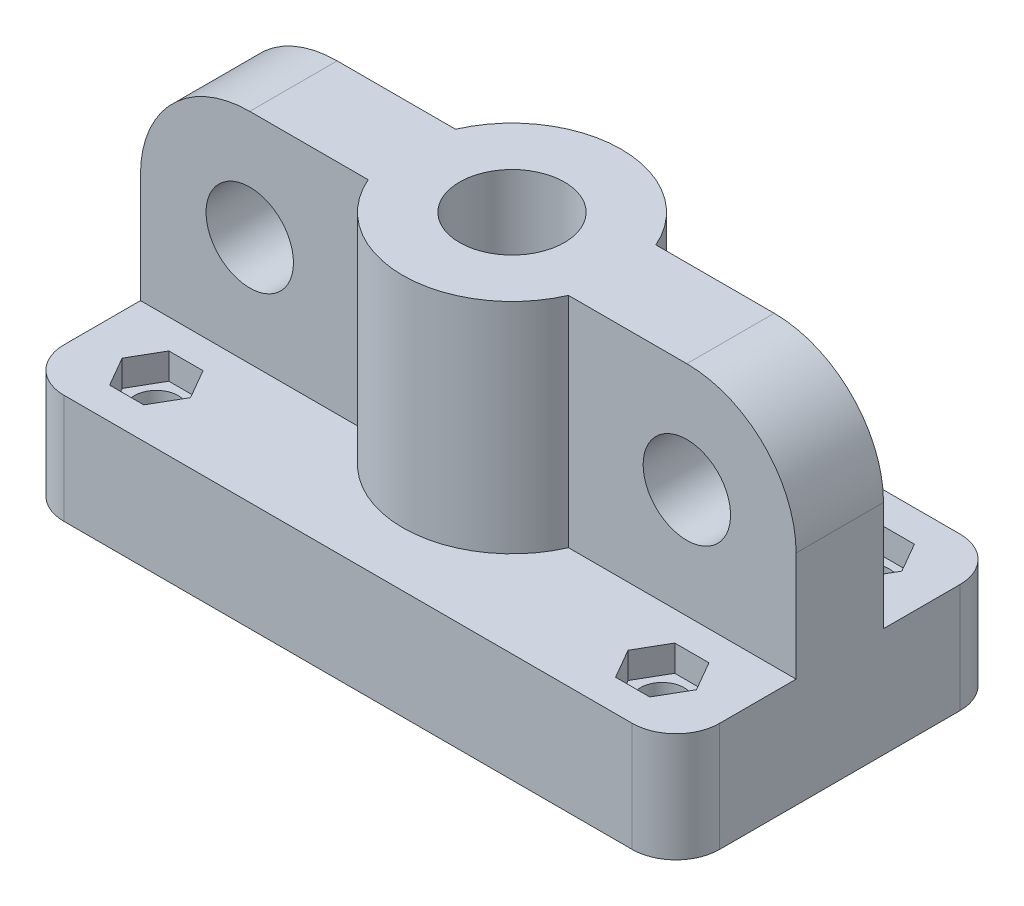
from build123d import *

# Parameters (mm, degrees)
SKETCH2_W           = 60
SKETCH2_H           = 30
BASE_DEPTH          = 10
STRUCTURE_DEPTH     = 20
SKETCH4_R           = 4
ELASTIC_HOLES_DEPTH = 20
SKETCH5_R           = 4.8
PEN_HOLE_DEPTH      = 31
UPPER_CORNER_DEC_R  = 10
BASE_CORNER_DEC_R   = 4
SKETCH6_R           = 2
BOLT_HOLES_DEPTH    = 31
CAP_NUT_HOLES_DEPTH = 2.4


with BuildPart() as part:
    # Sketch2 → Base (new body)
    with BuildSketch(Plane(origin=(0, 0, 0), x_dir=(1, 0, 0), z_dir=(0, 1, 0))):
        Rectangle(SKETCH2_W, SKETCH2_H)
    extrude(amount=BASE_DEPTH)

    # Sketch3 → Structure (add)
    with BuildSketch(Plane(origin=(0, 10, 0), x_dir=(1, 0, 0), z_dir=(0, 1, 0))):
        with BuildLine():
            Line((-9.16515139, 4), (-30, 4))
            Line((-30, 4), (-30, -4))
            Line((-30, -4), (-9.16515139, -4))
            ThreePointArc((-9.16515139, -4), (-10, 0), (-9.16515139, 4))
        make_face()
        with BuildLine():
            ThreePointArc((9.16515139, 4), (0, 10), (-9.16515139, 4))
            Line((-9.16515139, 4), (9.16515139, 4))
        make_face()
        with BuildLine():
            Line((9.16515139, 4), (-9.16515139, 4))
            ThreePointArc((-9.16515139, 4), (-10, 0), (-9.16515139, -4))
            Line((-9.16515139, -4), (9.16515139, -4))
            ThreePointArc((9.16515139, -4), (9.789063129, -2.043096437), (10, 0))
            ThreePointArc((10, 0), (9.789063129, 2.043096437), (9.16515139, 4))
        make_face()
        with BuildLine():
            Line((9.16515139, -4), (-9.16515139, -4))
            ThreePointArc((-9.16515139, -4), (0, -10), (9.16515139, -4))
        make_face()
        with BuildLine():
            Line((30, 4), (9.16515139, 4))
            ThreePointArc((9.16515139, 4), (9.789063129, 2.043096437), (10, 0))
            ThreePointArc((10, 0), (9.789063129, -2.043096437), (9.16515139, -4))
            Line((9.16515139, -4), (30, -4))
            Line((30, -4), (30, 4))
        make_face()
    extrude(amount=STRUCTURE_DEPTH)

    # Sketch4 → Elastic Holes (cut, through all)
    with BuildSketch(Plane.XY.offset(4)):
        with Locations((-20, 20)):
            Circle(SKETCH4_R)
        with Locations((20, 20)):
            Circle(SKETCH4_R)
    extrude(amount=-ELASTIC_HOLES_DEPTH, mode=Mode.SUBTRACT)

    # Sketch5 → Pen Hole (cut, through all)
    with BuildSketch(Plane(origin=(0, 30, 0), x_dir=(1, 0, 0), z_dir=(0, 1, 0))):
        Circle(SKETCH5_R)
    extrude(amount=-PEN_HOLE_DEPTH, mode=Mode.SUBTRACT)

    # Upper Corner Dec
    upper_corner_dec_edges = [part.edges().sort_by_distance(p)[0] for p in [
        (30, 30, 0),
        (-30, 30, 0),
    ]]
    fillet(upper_corner_dec_edges, radius=UPPER_CORNER_DEC_R)

    # Base Corner Dec
    base_corner_dec_edges = [part.edges().sort_by_distance(p)[0] for p in [
        (-30, 5, -15),
        (30, 5, -15),
        (30, 5, 15),
        (-30, 5, 15),
    ]]
    fillet(base_corner_dec_edges, radius=BASE_CORNER_DEC_R)

    # Sketch6 → Bolt Holes (cut, through all)
    with BuildSketch(Plane.XZ):
        with Locations((-23.15, 9.4)):
            Circle(SKETCH6_R)
        with Locations((23.15, 9.4)):
            Circle(SKETCH6_R)
        with Locations((23.15, -9.4)):
            Circle(SKETCH6_R)
        with Locations((-23.15, -9.4)):
            Circle(SKETCH6_R)
    extrude(amount=-BOLT_HOLES_DEPTH, mode=Mode.SUBTRACT)

    # Sketch7 → Cap Nut Holes (cut)
    with BuildSketch(Plane(origin=(0, 10, 0), x_dir=(1, 0, 0), z_dir=(0, 1, 0))):
        Polygon((-21.58538077, 12.11), (-24.71461923, 12.11), (-26.279238459, 9.4), (-24.71461923, 6.69), (-21.58538077, 6.69), (-20.020761541, 9.4), align=None)
        Polygon((20.020761541, 9.4), (21.58538077, 12.11), (24.71461923, 12.11), (26.279238459, 9.4), (24.71461923, 6.69), (21.58538077, 6.69), align=None)
        Polygon((21.58538077, -12.11), (24.71461923, -12.11), (26.279238459, -9.4), (24.71461923, -6.69), (21.58538077, -6.69), (20.020761541, -9.4), align=None)
        Polygon((-20.020761541, -9.4), (-21.58538077, -12.11), (-24.71461923, -12.11), (-26.279238459, -9.4), (-24.71461923, -6.69), (-21.58538077, -6.69), align=None)
    extrude(amount=-CAP_NUT_HOLES_DEPTH, mode=Mode.SUBTRACT)


solid = part.part
